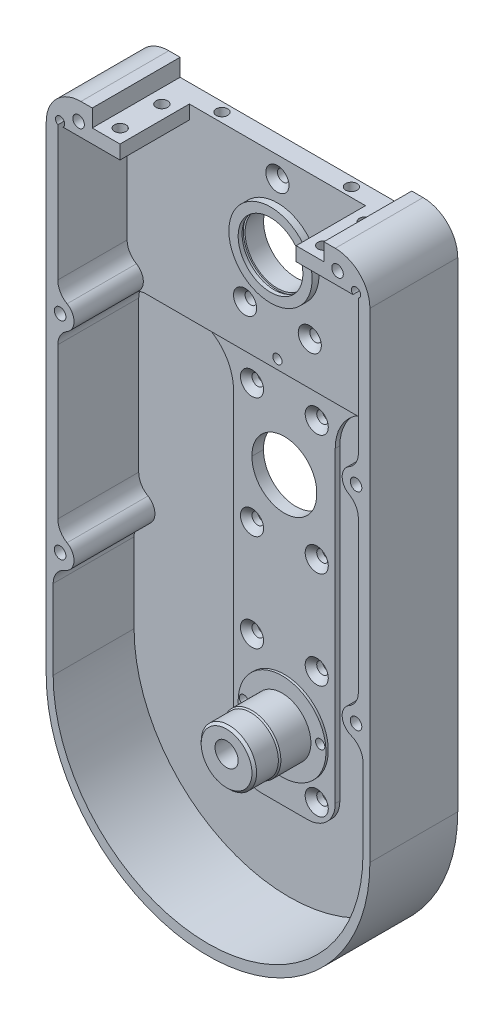
from build123d import *

# Parameters (mm, degrees)
BOSS_EXTRUDE1_DEPTH                = 38
CUT_EXTRUDE1_DEPTH                 = 30
CUT_EXTRUDE2_DEPTH                 = 5
SKETCH4_W                          = 19.9
SKETCH4_H                          = 38
BOSS_EXTRUDE2_DEPTH                = 7.5
SKETCH5_W                          = 19.9
SKETCH5_H                          = 38
BOSS_EXTRUDE3_DEPTH                = 7.5
CUT_EXTRUDE3_DEPTH                 = 30
CUT_EXTRUDE4_DEPTH                 = 30
SKETCH8_W                          = 44
SKETCH8_H                          = 165
BOSS_EXTRUDE4_DEPTH                = 2
SKETCH9_W                          = 18
SKETCH9_H                          = 3
F_4_0_4_DIAMETER_HOLE1_D           = 4
F_4_0_4_DIAMETER_HOLE1_DEPTH       = 38
F_4_0_4_DIAMETER_HOLE2_D           = 4
F_4_0_4_DIAMETER_HOLE2_DEPTH       = 38
F_5_0_5_DIAMETER_HOLE1_D           = 5
M24_CLEARANCE_HOLE1_D              = 28
F_10_0_10_DIAMETER_HOLE1_D         = 10
F_10_0_10_DIAMETER_HOLE1_DEPTH     = 38
F_5_0_5_DIAMETER_HOLE2_D           = 5
F_5_0_5_DIAMETER_HOLE2_CSINK_D     = 10.000000842
F_5_0_5_DIAMETER_HOLE2_CSINK_ANGLE = 90.00001
F_5_0_5_DIAMETER_HOLE3_D           = 5
F_5_0_5_DIAMETER_HOLE3_DEPTH       = 6
F_5_0_5_DIAMETER_HOLE4_D           = 5
F_5_0_5_DIAMETER_HOLE4_DEPTH       = 20
F_5_0_5_DIAMETER_HOLE5_D           = 5
F_5_0_5_DIAMETER_HOLE5_DEPTH       = 35
F_5_0_5_DIAMETER_HOLE6_D           = 5
F_5_0_5_DIAMETER_HOLE6_DEPTH       = 30
CHAMFER1_SIZE                      = 2.50000021
CHAMFER1_SIZE2                     = 2.499999787
CHAMFER2_SIZE                      = 1
FILLET1_R                          = 8
FILLET2_R                          = 12
FILLET3_R                          = 15
FILLET4_R                          = 20
SKETCH32_R                         = 14
CUT_EXTRUDE5_DEPTH                 = 261.84441723


with BuildPart() as part:
    # Sketch1 → Boss-Extrude1 (new body)
    with BuildSketch(Plane.XY.offset(38)):
        with BuildLine():
            Line((70, 36), (-70, 36))
            Line((-70, 36), (-70, -179.1))
            ThreePointArc((-70, -179.1), (0, -249.1), (70, -179.1))
            Line((70, -179.1), (70, 36))
        make_face()
    extrude(amount=-BOSS_EXTRUDE1_DEPTH)

    # Sketch2 → Cut-Extrude1 (cut)
    with BuildSketch(Plane.XY.offset(38)):
        with BuildLine():
            Line((-38.1, 36), (-38.1, 30))
            Line((-38.1, 30), (-65, 30))
            Line((-65, 30), (-65, -34.583920217))
            ThreePointArc((-65, -34.583920217), (-58.354610186, -38.467864707), (-61, -45.696152423))
            ThreePointArc((-61, -45.696152423), (-63.92820323, -48.624355653), (-65, -52.624355653))
            Line((-65, -52.624355653), (-65, -124.083920217))
            ThreePointArc((-65, -124.083920217), (-58.211536441, -128.420857946), (-61.857142857, -135.604298642))
            ThreePointArc((-61.857142857, -135.604298642), (-65.590035768, -138.541123155), (-67, -143.076696831))
            Line((-67, -143.076696831), (-67, -177.5))
            ThreePointArc((-67, -177.5), (0, -244.5), (67, -177.5))
            Line((67, -177.5), (67, -143.076696831))
            ThreePointArc((67, -143.076696831), (65.590035768, -138.541123155), (61.857142857, -135.604298642))
            ThreePointArc((61.857142857, -135.604298642), (58.211536441, -128.420857946), (65, -124.083920217))
            Line((65, -124.083920217), (65, -52.624355653))
            ThreePointArc((65, -52.624355653), (63.92820323, -48.624355653), (61, -45.696152423))
            ThreePointArc((61, -45.696152423), (58.354610186, -38.467864707), (65, -34.583920217))
            Line((65, -34.583920217), (65, 30))
            Line((65, 30), (38.1, 30))
            Line((38.1, 30), (38.1, 36))
            Line((38.1, 36), (-38.1, 36))
        make_face()
    extrude(amount=-CUT_EXTRUDE1_DEPTH, mode=Mode.SUBTRACT)

    # Sketch3 → Cut-Extrude2 (cut)
    with BuildSketch(Plane.XY.offset(8)):
        with BuildLine():
            Line((56.928932188, -44.5), (-56.928932188, -44.5))
            ThreePointArc((-56.928932188, -44.5), (-58.97017364, -44.783121635), (-60.857303195, -45.611111111))
            ThreePointArc((-60.857303195, -45.611111111), (-60.928357277, -45.654125627), (-61, -45.696152423))
            ThreePointArc((-61, -45.696152423), (-63.92820323, -48.624355653), (-65, -52.624355653))
            Line((-65, -52.624355653), (-65, -124.083920217))
            ThreePointArc((-65, -124.083920217), (-58.211536441, -128.420857946), (-61.857142857, -135.604298642))
            ThreePointArc((-61.857142857, -135.604298642), (-65.590035768, -138.541123155), (-67, -143.076696831))
            Line((-67, -143.076696831), (-67, -177.5))
            ThreePointArc((-67, -177.5), (0, -244.5), (67, -177.5))
            Line((67, -177.5), (67, -143.076696831))
            ThreePointArc((67, -143.076696831), (65.590035768, -138.541123155), (61.857142857, -135.604298642))
            ThreePointArc((61.857142857, -135.604298642), (58.211536441, -128.420857946), (65, -124.083920217))
            Line((65, -124.083920217), (65, -52.624355653))
            ThreePointArc((65, -52.624355653), (63.92820323, -48.624355653), (61, -45.696152423))
            ThreePointArc((61, -45.696152423), (60.928357277, -45.654125627), (60.857303195, -45.611111111))
            ThreePointArc((60.857303195, -45.611111111), (58.97017364, -44.783121635), (56.928932188, -44.5))
        make_face()
    extrude(amount=-CUT_EXTRUDE2_DEPTH, mode=Mode.SUBTRACT)

    # Sketch4 → Boss-Extrude2 (add)
    with BuildSketch(Plane(origin=(0, 36, 0), x_dir=(-1, 0, 0), z_dir=(0, 1, 0))):
        with Locations((-60.05, 19)):
            Rectangle(SKETCH4_W, SKETCH4_H)
    extrude(amount=BOSS_EXTRUDE2_DEPTH)

    # Sketch5 → Boss-Extrude3 (add)
    with BuildSketch(Plane(origin=(0, 36, 0), x_dir=(-1, 0, 0), z_dir=(0, 1, 0))):
        with Locations((60.05, 19)):
            Rectangle(SKETCH5_W, SKETCH5_H)
    extrude(amount=BOSS_EXTRUDE3_DEPTH)

    # Sketch6 → Cut-Extrude3 (cut)
    with BuildSketch(Plane.XY.offset(38)):
        with BuildLine():
            Line((-65, 30), (-62.677124344, 30))
            ThreePointArc((-62.677124344, 30), (-64.198806606, 33.490094453), (-65, 29.767949192))
            Line((-65, 29.767949192), (-65, 30))
        make_face()
    extrude(amount=-CUT_EXTRUDE3_DEPTH, mode=Mode.SUBTRACT)

    # Sketch7 → Cut-Extrude4 (cut)
    with BuildSketch(Plane.XY.offset(38)):
        with BuildLine():
            Line((65, 30), (65, 29.767949192))
            ThreePointArc((65, 29.767949192), (64.198806606, 33.490094453), (62.677124344, 30))
            Line((62.677124344, 30), (65, 30))
        make_face()
    extrude(amount=-CUT_EXTRUDE4_DEPTH, mode=Mode.SUBTRACT)

    # Sketch8 → Boss-Extrude4 (add)
    with BuildSketch(Plane.XY.offset(3)):
        with Locations((0, -127)):
            Rectangle(SKETCH8_W, SKETCH8_H)
    extrude(amount=BOSS_EXTRUDE4_DEPTH)

    # Sketch9 → Revolve1 (revolve)
    with BuildSketch(Plane.XZ):
        with Locations((9, 9.5)):
            Rectangle(SKETCH9_W, SKETCH9_H)
    revolve(axis=Axis((0, 0, 11), (0, 0, -1)))

    # Sketch10 → Revolve2 (revolve)
    with BuildSketch(Plane.XZ.offset(179.1)):
        Polygon((11.98, 30), (0, 30), (0, 5), (19, 5), (19, 6), (12.48, 6), (12.48, 19), (11.98, 19.575184204), align=None)
    revolve(axis=Axis((0, -179.1, 30), (0, 0, -1)))

    # Sketch11 → Cut-Revolve1 (revolve, cut)
    with BuildSketch(Plane.XZ):
        Polygon((14, 11), (0, 11), (0, 0), (14, 0), (14, 8), (14.75, 8), (14.75, 9.3), (14, 9.3), align=None)
    revolve(axis=Axis((0, 0, 11), (0, 0, -1)), mode=Mode.SUBTRACT)

    # Ø4.0 (4) Diameter Hole1
    with Locations(Plane(origin=(0, 0, 0), x_dir=(-1, 0, 0), z_dir=(0, 0, -1))):
        with Locations((-16.5, -177.5), (16.5, -177.5)):
            Hole(F_4_0_4_DIAMETER_HOLE1_D / 2, depth=F_4_0_4_DIAMETER_HOLE1_DEPTH)

    # Ø4.0 (4) Diameter Hole2
    with Locations(Plane(origin=(0, 0, 0), x_dir=(-1, 0, 0), z_dir=(0, 0, -1))):
        with Locations((0, -40.5)):
            Hole(F_4_0_4_DIAMETER_HOLE2_D / 2, depth=F_4_0_4_DIAMETER_HOLE2_DEPTH)

    # Ø5.0 (5) Diameter Hole1 (through all)
    with Locations(Plane.XY.offset(8)):
        with Locations((14, -26), (-14, -26), (0, 27)):
            Hole(F_5_0_5_DIAMETER_HOLE1_D / 2)

    # M24 Clearance Hole1 (through all)
    with Locations(Plane.XY.offset(5)):
        with Locations((0, -85)):
            Hole(M24_CLEARANCE_HOLE1_D / 2)

    # Ø10.0 (10) Diameter Hole1
    with Locations(Plane(origin=(0, 0, 0), x_dir=(-1, 0, 0), z_dir=(0, 0, -1))):
        with Locations((0, -177.5)):
            Hole(F_10_0_10_DIAMETER_HOLE1_D / 2, depth=F_10_0_10_DIAMETER_HOLE1_DEPTH)

    # Ø5.0 (5) Diameter Hole2 (through all)
    with Locations(Plane.XY.offset(5)):
        with Locations((14, -201), (-14, -201), (-14, -152), (14, -152), (-14, -110), (14, -110), (-14, -58), (14, -58)):
            CounterSinkHole(F_5_0_5_DIAMETER_HOLE2_D / 2, F_5_0_5_DIAMETER_HOLE2_CSINK_D / 2, counter_sink_angle=F_5_0_5_DIAMETER_HOLE2_CSINK_ANGLE)

    # Ø5.0 (5) Diameter Hole3
    with Locations(Plane(origin=(0, 36, 0), x_dir=(1, 0, 0), z_dir=(0, 1, 0))):
        with Locations((44, -14), (44, -32), (-44, -32), (-44, -14)):
            Hole(F_5_0_5_DIAMETER_HOLE3_D / 2, depth=F_5_0_5_DIAMETER_HOLE3_DEPTH)

    # Ø5.0 (5) Diameter Hole4
    with Locations(Plane(origin=(0, 36, 0), x_dir=(1, 0, 0), z_dir=(0, 1, 0))):
        with Locations((28, -4), (-28, -4)):
            Hole(F_5_0_5_DIAMETER_HOLE4_D / 2, depth=F_5_0_5_DIAMETER_HOLE4_DEPTH)

    # Ø5.0 (5) Diameter Hole5
    with Locations(Plane.XY.offset(38)):
        with Locations((64, -130), (-64, -130)):
            Hole(F_5_0_5_DIAMETER_HOLE5_D / 2, depth=F_5_0_5_DIAMETER_HOLE5_DEPTH)

    # Ø5.0 (5) Diameter Hole6
    with Locations(Plane.XY.offset(38)):
        with Locations((-56, 35.5), (56, 35.5), (64, -40.5), (-64, -40.5)):
            Hole(F_5_0_5_DIAMETER_HOLE6_D / 2, depth=F_5_0_5_DIAMETER_HOLE6_DEPTH)

    # Chamfer1
    chamfer1_edges = [part.edges().sort_by_distance(p)[0] for p in [
        (16.5, -26, 8),
        (-11.5, -26, 8),
        (2.5, 27, 8),
    ]]
    chamfer1_side = [part.faces().sort_by_distance(p)[0] for p in [
        (0, 34.448085909, 8),
    ]]
    chamfer(chamfer1_edges, length=CHAMFER1_SIZE, length2=CHAMFER1_SIZE2, reference=chamfer1_side[0])

    # Chamfer2
    chamfer2_edges = [part.edges().sort_by_distance(p)[0] for p in [
        (-11.98, -179.1, 30),
    ]]
    chamfer(chamfer2_edges, length=CHAMFER2_SIZE)

    # Fillet1
    fillet1_edges = [part.edges().sort_by_distance(p)[0] for p in [
        (-65, -34.583920217, 23),
        (65, -124.083920217, 20.5),
        (65, -34.583920217, 23),
        (-65, -124.083920217, 20.5),
    ]]
    fillet(fillet1_edges, radius=FILLET1_R)

    # Fillet2
    fillet2_edges = [part.edges().sort_by_distance(p)[0] for p in [
        (22, -209.5, 4),
        (-22, -209.5, 4),
    ]]
    fillet(fillet2_edges, radius=FILLET2_R)

    # Fillet3
    fillet3_edges = [part.edges().sort_by_distance(p)[0] for p in [
        (-70, 43.5, 19),
        (70, 43.5, 19),
    ]]
    fillet(fillet3_edges, radius=FILLET3_R)

    # Fillet4
    fillet4_edges = [part.edges().sort_by_distance(p)[0] for p in [
        (-22, -44.5, 4),
        (22, -44.5, 4),
    ]]
    fillet(fillet4_edges, radius=FILLET4_R)

    # Sketch32 → Cut-Extrude5 (cut, through all)
    with BuildSketch(Plane.XY.offset(5)):
        with Locations((0, -85.75)):
            Circle(SKETCH32_R)
    extrude(amount=-CUT_EXTRUDE5_DEPTH, mode=Mode.SUBTRACT)


solid = part.part
